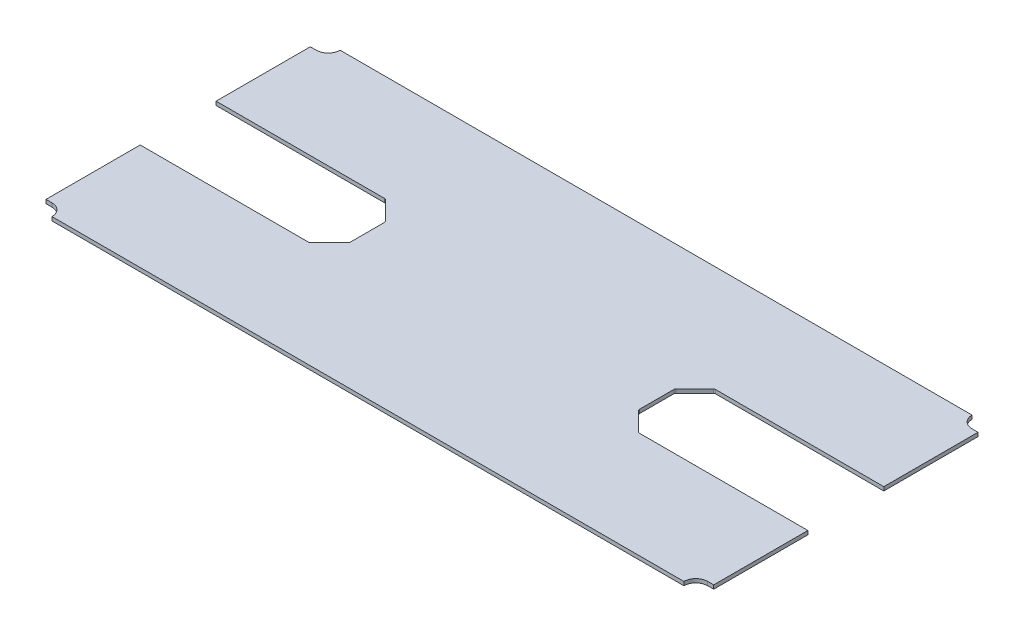
from build123d import *

# Parameters (mm, degrees)
BOSS_EXTRUDE1_DEPTH = 9.525
CHAMFER1_SIZE       = 50
FILLET2_R           = 5


with BuildPart() as part:
    # Sketch1 → Boss-Extrude1 (new body)
    with BuildSketch(Plane(origin=(0, 0, 0), x_dir=(1, 0, 0), z_dir=(0, 1, 0))):
        with BuildLine():
            Line((-840, 332.5), (-840, 95.5))
            Line((-840, 95.5), (-364, 95.5))
            Line((-364, 95.5), (-364, -95.5))
            Line((-364, -95.5), (-840, -95.5))
            Line((-840, -95.5), (-840, -332.5))
            Line((-840, -332.5), (-825, -332.5))
            ThreePointArc((-825, -332.5), (-803.786796564, -341.286796564), (-795, -362.5))
            Line((-795, -362.5), (795, -362.5))
            ThreePointArc((795, -362.5), (803.786796564, -341.286796564), (825, -332.5))
            Line((825, -332.5), (840, -332.5))
            Line((840, -332.5), (840, -95.5))
            Line((840, -95.5), (364, -95.5))
            Line((364, -95.5), (364, 95.5))
            Line((364, 95.5), (840, 95.5))
            Line((840, 95.5), (840, 332.5))
            Line((840, 332.5), (825, 332.5))
            ThreePointArc((825, 332.5), (803.786796564, 341.286796564), (795, 362.5))
            Line((795, 362.5), (-795, 362.5))
            ThreePointArc((-795, 362.5), (-803.786796564, 341.286796564), (-825, 332.5))
            Line((-825, 332.5), (-840, 332.5))
        make_face()
    extrude(amount=BOSS_EXTRUDE1_DEPTH)

    # Chamfer1
    chamfer1_edges = [part.edges().sort_by_distance(p)[0] for p in [
        (-364, 4.7625, 95.5),
        (-364, 4.7625, -95.5),
        (364, 4.7625, -95.5),
        (364, 4.7625, 95.5),
    ]]
    chamfer(chamfer1_edges, length=CHAMFER1_SIZE)

    # Fillet2
    fillet2_edges = [part.edges().sort_by_distance(p)[0] for p in [
        (364, 4.7625, -45.5),
        (364, 4.7625, 45.5),
        (414, 4.7625, 95.5),
        (414, 4.7625, -95.5),
        (-414, 4.7625, 95.5),
        (-364, 4.7625, -45.5),
        (-364, 4.7625, 45.5),
        (-414, 4.7625, -95.5),
    ]]
    fillet(fillet2_edges, radius=FILLET2_R)


solid = part.part
